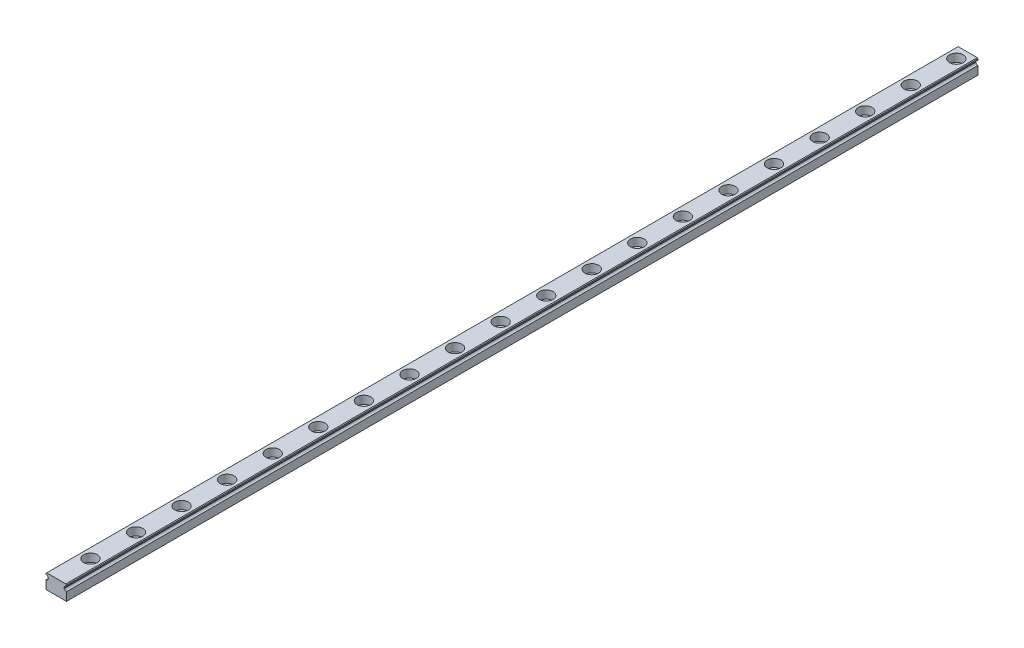
from build123d import *

# Parameters (mm, degrees)
EXTRUDE1_DEPTH  = 400
SKETCH2_R       = 3
EXTRUDE2_DEPTH  = 3.5
SKETCH_R        = 1.75
EXTRUDE3_DEPTH  = 401.078117372
LPATTERN1_COUNT = 40
LPATTERN1_PITCH = 20
CHAMFER1_SIZE   = 0.3


with BuildPart() as part:
    # Sketch1 → Extrude1 (new body)
    with BuildSketch(Plane.XY):
        with BuildLine():
            Line((-4.5, -3.25), (4.5, -3.25))
            Line((4.5, -3.25), (4.5, 0.45))
            ThreePointArc((4.5, 0.45), (3.887627564, 0.659430585), (3.531754163, 1.2))
            Line((3.531754163, 1.2), (3.4, 1.2))
            Line((3.4, 1.2), (3.4, 1.7))
            Line((3.4, 1.7), (3.531754163, 1.7))
            ThreePointArc((3.531754163, 1.7), (3.887627564, 2.240569415), (4.5, 2.45))
            Line((4.5, 2.45), (4.5, 3.25))
            Line((4.5, 3.25), (-4.5, 3.25))
            Line((-4.5, 3.25), (-4.5, 2.45))
            ThreePointArc((-4.5, 2.45), (-3.887627564, 2.240569415), (-3.531754163, 1.7))
            Line((-3.531754163, 1.7), (-3.4, 1.7))
            Line((-3.4, 1.7), (-3.4, 1.2))
            Line((-3.4, 1.2), (-3.531754163, 1.2))
            ThreePointArc((-3.531754163, 1.2), (-3.887627564, 0.659430585), (-4.5, 0.45))
            Line((-4.5, 0.45), (-4.5, -3.25))
        make_face()
    extrude(amount=EXTRUDE1_DEPTH)

    # Sketch2 → Extrude2 (cut)
    with BuildSketch(Plane(origin=(0, 3.25, 0), x_dir=(1, 0, 0), z_dir=(0, 1, 0))):
        with Locations((0, -5)):
            Circle(SKETCH2_R)
    extrude2 = extrude(amount=-EXTRUDE2_DEPTH, mode=Mode.SUBTRACT)

    # Sketch → Extrude3 (cut, through all)
    with BuildSketch(Plane(origin=(0, 3.25, 0), x_dir=(1, 0, 0), z_dir=(0, 1, 0))):
        with Locations((0, -5)):
            Circle(SKETCH_R)
    extrude3 = extrude(amount=-EXTRUDE3_DEPTH, mode=Mode.SUBTRACT)

    # LPattern1: Extrude2, Extrude3 ×40
    with Locations(*[(0, 0, i * LPATTERN1_PITCH) for i in range(1, LPATTERN1_COUNT)]):
        add(extrude2, mode=Mode.SUBTRACT)
        add(extrude3, mode=Mode.SUBTRACT)

    # Chamfer1
    chamfer1_edges = [part.edges().sort_by_distance(p)[0] for p in [
        (4.5, 3.25, 200),
        (-4.5, 3.25, 200),
    ]]
    chamfer(chamfer1_edges, length=CHAMFER1_SIZE)


solid = part.part
